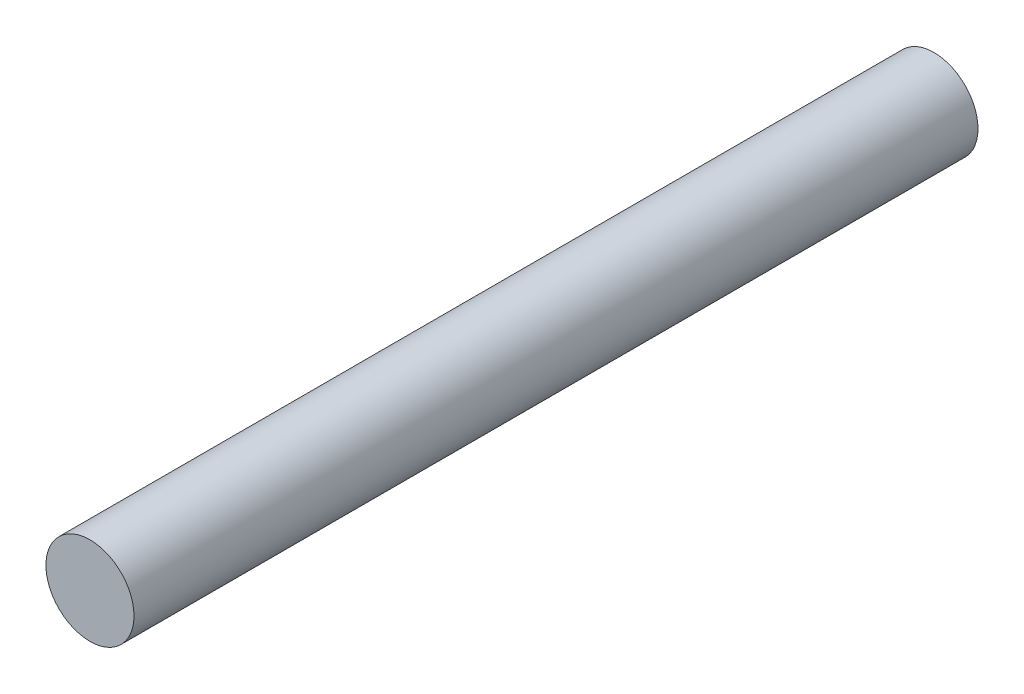
from build123d import *

# Parameters (mm, degrees)
SKETCH_1_R      = 6
EXTRUDE_1_DEPTH = 115


with BuildPart() as part:
    # 草圖1 → 填料-伸長1 (new body)
    with BuildSketch(Plane.XY):
        Circle(SKETCH_1_R)
    extrude(amount=EXTRUDE_1_DEPTH)


solid = part.part
